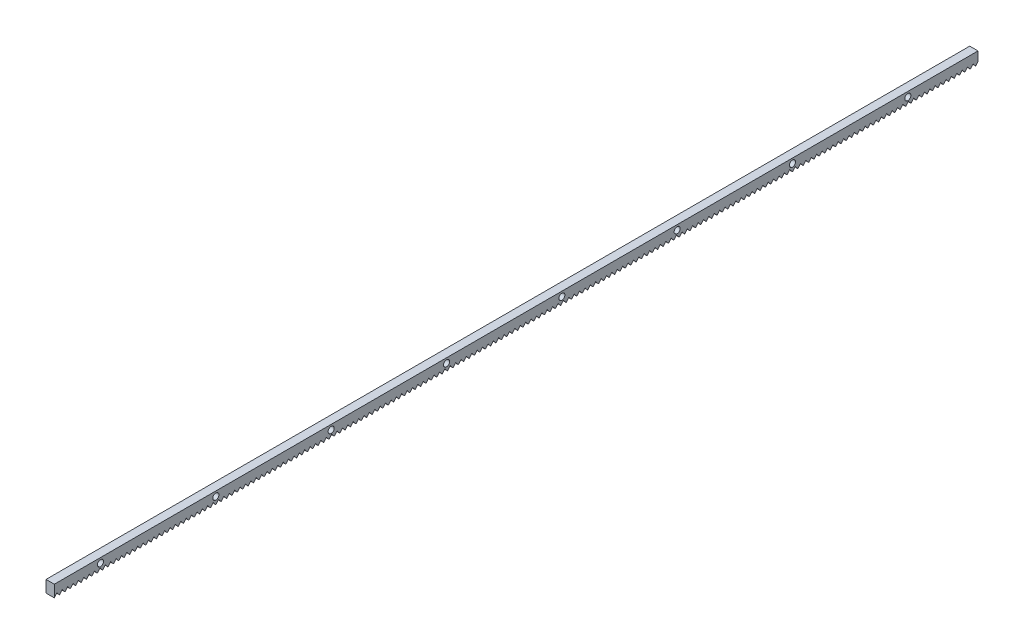
from build123d import *

# Parameters (mm, degrees)
SKETCH1_W           = 7.7
SKETCH1_H           = 11
BOSS_EXTRUDE1_DEPTH = 857
SKETCH2_R           = 2.838222715
CUT_EXTRUDE1_DEPTH  = 900
LPATTERN1_COUNT     = 10
LPATTERN1_PITCH     = 107
CUT_EXTRUDE2_DEPTH  = 900
LPATTERN2_COUNT     = 200
LPATTERN2_PITCH     = 5


with BuildPart() as part:
    # Sketch1 → Boss-Extrude1 (new body)
    with BuildSketch(Plane.XY):
        with Locations((-17.098175182, -1.01459854)):
            Rectangle(SKETCH1_W, SKETCH1_H)
    extrude(amount=BOSS_EXTRUDE1_DEPTH)

    # Sketch2 → Cut-Extrude1 (cut)
    with BuildSketch(Plane(origin=(-13.248175182, 0, 0), x_dir=(0, 0, -1), z_dir=(1, 0, 0))):
        with Locations((-814.107905512, 0)):
            Circle(SKETCH2_R)
    cut_extrude1 = extrude(amount=-CUT_EXTRUDE1_DEPTH, mode=Mode.SUBTRACT)

    # LPattern1: Cut-Extrude1 ×10
    with Locations(*[(0, 0, -i * LPATTERN1_PITCH) for i in range(1, LPATTERN1_COUNT)]):
        add(cut_extrude1, mode=Mode.SUBTRACT)

    # Sketch3 → Cut-Extrude2 (cut)
    with BuildSketch(Plane(origin=(-13.248175182, 0, 0), x_dir=(0, 0, -1), z_dir=(1, 0, 0))):
        Polygon((-857.109435316, -6.63011724), (-854.609435316, -3.590375107), (-852.109435316, -6.63011724), align=None)
    cut_extrude2 = extrude(amount=-CUT_EXTRUDE2_DEPTH, mode=Mode.SUBTRACT)

    # LPattern2: Cut-Extrude2 ×200
    with Locations(*[(0, 0, -i * LPATTERN2_PITCH) for i in range(1, LPATTERN2_COUNT)]):
        add(cut_extrude2, mode=Mode.SUBTRACT)


solid = part.part
